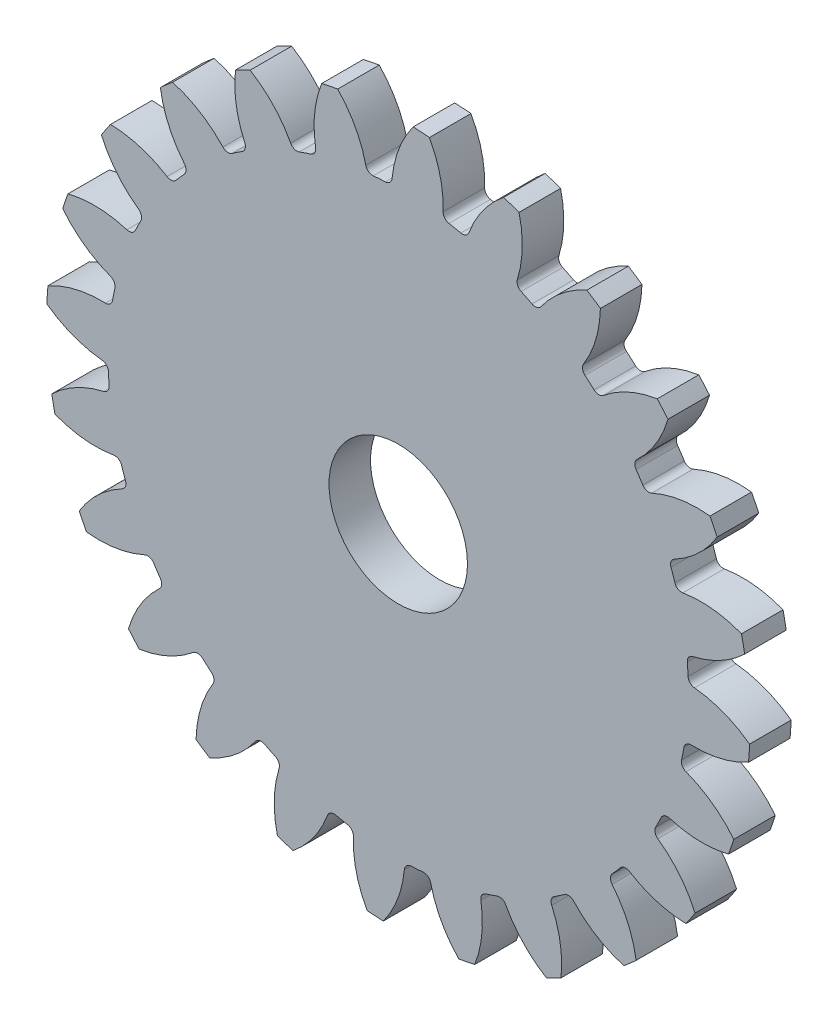
from build123d import *

# Parameters (mm, degrees)
CROQUIS1_R              = 25.4
SALIENTE_EXTRUIR1_DEPTH = 3
CORTAR_EXTRUIR1_DEPTH   = 4
REDONDEO1_R             = 0.508
MATRIZC1_COUNT          = 24
REDONDEO1_OF_MATRIZC1_R = 0.508
CROQUIS3_R              = 5
CORTAR_EXTRUIR2_DEPTH   = 4.0000001


with BuildPart() as part:
    # Croquis1 → Saliente-Extruir1 (new body)
    with BuildSketch(Plane.XY):
        Circle(CROQUIS1_R)
    extrude(amount=SALIENTE_EXTRUIR1_DEPTH)

    # Croquis2 → Cortar-Extruir1 (cut, through all)
    with BuildSketch(Plane.XY.offset(3)):
        with BuildLine():
            ThreePointArc((1.077270786, 25.377144986), (-1.656521739, 25.345925427), (-4.371122388, 25.021056914))
            ThreePointArc((-4.371122388, 25.021056914), (-2.998832023, 23.085970621), (-2.255005124, 20.833314112))
            ThreePointArc((-2.255005124, 20.833314112), (-1.366630435, 20.910388477), (-0.475781032, 20.949598025))
            ThreePointArc((-0.475781032, 20.949598025), (-0.031480816, 23.2799064), (1.077270786, 25.377144986))
        make_face()
    cortar_extruir1 = extrude(amount=-CORTAR_EXTRUIR1_DEPTH, mode=Mode.SUBTRACT)

    # Redondeo1
    redondeo1_edges = [part.edges().sort_by_distance(p)[0] for p in [
        (-0.475781032, 20.949598025, 1.5),
        (-2.255005124, 20.833314112, 1.5),
    ]]
    fillet(redondeo1_edges, radius=REDONDEO1_R)

    # MatrizC1: Cortar-Extruir1 ×24 about axis
    matrizc1_axis = Axis((0, 0, 0), (0, 0, 1))
    for i in range(1, MATRIZC1_COUNT):
        add(cortar_extruir1.rotate(matrizc1_axis, i * 360 / MATRIZC1_COUNT), mode=Mode.SUBTRACT)

    # Redondeo1 of MatrizC1
    redondeo1_of_matrizc1_edges = [part.edges().sort_by_distance(p)[0] for p in [
        (-5.881724143, 20.11261659, 1.5),
        (-7.570226153, 19.539797875, 1.5),
        (-10.886837473, 17.904993573, 1.5),
        (-12.369548779, 16.914676704, 1.5),
        (-15.150030821, 14.477174832, 1.5),
        (-16.325907098, 13.136848268, 1.5),
        (-18.380774605, 10.062760552, 1.5),
        (-19.169681828, 8.463765333, 1.5),
        (-20.358898975, 4.962585769, 1.5),
        (-20.707074421, 3.213890777, 1.5),
        (-20.949598025, -0.475781032, 1.5),
        (-20.833314112, -2.255005124, 1.5),
        (-20.11261659, -5.881724143, 1.5),
        (-19.539797875, -7.570226153, 1.5),
        (-17.904993573, -10.886837473, 1.5),
        (-16.914676704, -12.369548779, 1.5),
        (-14.477174832, -15.150030821, 1.5),
        (-13.136848268, -16.325907098, 1.5),
        (-10.062760552, -18.380774605, 1.5),
        (-8.463765333, -19.169681828, 1.5),
        (-4.962585769, -20.358898975, 1.5),
        (-3.213890777, -20.707074421, 1.5),
        (0.475781032, -20.949598025, 1.5),
        (2.255005124, -20.833314112, 1.5),
        (5.881724143, -20.11261659, 1.5),
        (7.570226153, -19.539797875, 1.5),
        (10.886837473, -17.904993573, 1.5),
        (12.369548779, -16.914676704, 1.5),
        (15.150030821, -14.477174832, 1.5),
        (16.325907098, -13.136848268, 1.5),
        (18.380774605, -10.062760552, 1.5),
        (19.169681828, -8.463765333, 1.5),
        (20.358898975, -4.962585769, 1.5),
        (20.707074421, -3.213890777, 1.5),
        (20.949598025, 0.475781032, 1.5),
        (20.833314112, 2.255005124, 1.5),
        (20.11261659, 5.881724143, 1.5),
        (19.539797875, 7.570226153, 1.5),
        (17.904993573, 10.886837473, 1.5),
        (16.914676704, 12.369548779, 1.5),
        (14.477174832, 15.150030821, 1.5),
        (13.136848268, 16.325907098, 1.5),
        (10.062760552, 18.380774605, 1.5),
        (8.463765333, 19.169681828, 1.5),
        (4.962585769, 20.358898975, 1.5),
        (3.213890777, 20.707074421, 1.5),
    ]]
    fillet(redondeo1_of_matrizc1_edges, radius=REDONDEO1_OF_MATRIZC1_R)

    # Croquis3 → Cortar-Extruir2 (cut, through all)
    with BuildSketch(Plane.XY.offset(3)):
        Circle(CROQUIS3_R)
    extrude(amount=-CORTAR_EXTRUIR2_DEPTH, mode=Mode.SUBTRACT)


solid = part.part
